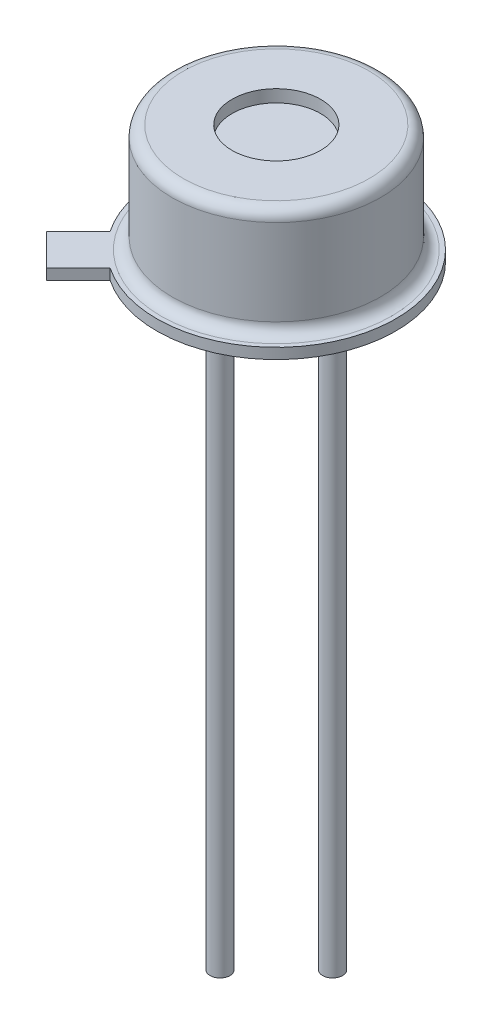
from build123d import *

# Parameters (mm, degrees)
BOSS_EXTRUDE1_DEPTH = 0.24
SKETCH3_R           = 2.35
BOSS_EXTRUDE2_DEPTH = 2.44
SKETCH4_R           = 1
CUT_EXTRUDE1_DEPTH  = 0.2794
SKETCH6_R           = 0.225
BOSS_EXTRUDE3_DEPTH = 13.2
FILLET1_R           = 0.25


with BuildPart() as part:
    # Sketch1 → Boss-Extrude1 (new body)
    with BuildSketch(Plane(origin=(0, 0, 0), x_dir=(1, 0, 0), z_dir=(0, 1, 0))):
        with BuildLine():
            Line((-2.234301709, -1.51588122), (-2.952722199, -2.234301709))
            Line((-2.952722199, -2.234301709), (-2.234301709, -2.952722199))
            Line((-2.234301709, -2.952722199), (-1.51588122, -2.234301709))
            ThreePointArc((-1.51588122, -2.234301709), (1.909188309, 1.909188309), (-2.234301709, -1.51588122))
        make_face()
    extrude(amount=BOSS_EXTRUDE1_DEPTH)

    # Sketch3 → Boss-Extrude2 (add)
    with BuildSketch(Plane(origin=(0, 0.24, 0), x_dir=(1, 0, 0), z_dir=(0, 1, 0))):
        with Locations(Location((0, 0, 0), (0, 0, 270))):  # turned: the seam where the file's is
            Circle(SKETCH3_R)
    extrude(amount=BOSS_EXTRUDE2_DEPTH)

    # Sketch4 → Cut-Extrude1 (cut)
    with BuildSketch(Plane(origin=(0, 2.68, 0), x_dir=(1, 0, 0), z_dir=(0, 1, 0))):
        with Locations(Location((0, 0, 0), (0, 0, 270))):  # turned: the seam where the file's is
            Circle(SKETCH4_R)
    extrude(amount=-CUT_EXTRUDE1_DEPTH, mode=Mode.SUBTRACT)

    # Sketch6 → Boss-Extrude3 (add)
    with BuildSketch(Plane.XZ):
        with Locations(Location((0, 1.27, 0), (0, 0, 90))):  # turned: the seam where the file's is
            Circle(SKETCH6_R)
        with Locations(Location((0, -1.27, 0), (0, 0, 90))):  # turned: the seam where the file's is
            Circle(SKETCH6_R)
        with Locations(Location((1.27, 0, 0), (0, 0, 90))):  # turned: the seam where the file's is
            Circle(SKETCH6_R)
    extrude(amount=BOSS_EXTRUDE3_DEPTH)

    # Fillet1
    fillet1_edges = [part.edges().sort_by_distance(p)[0] for p in [
        (0, 0.24, -2.35),
        (0, 2.68, -2.35),
    ]]
    fillet(fillet1_edges, radius=FILLET1_R)


solid = part.part
